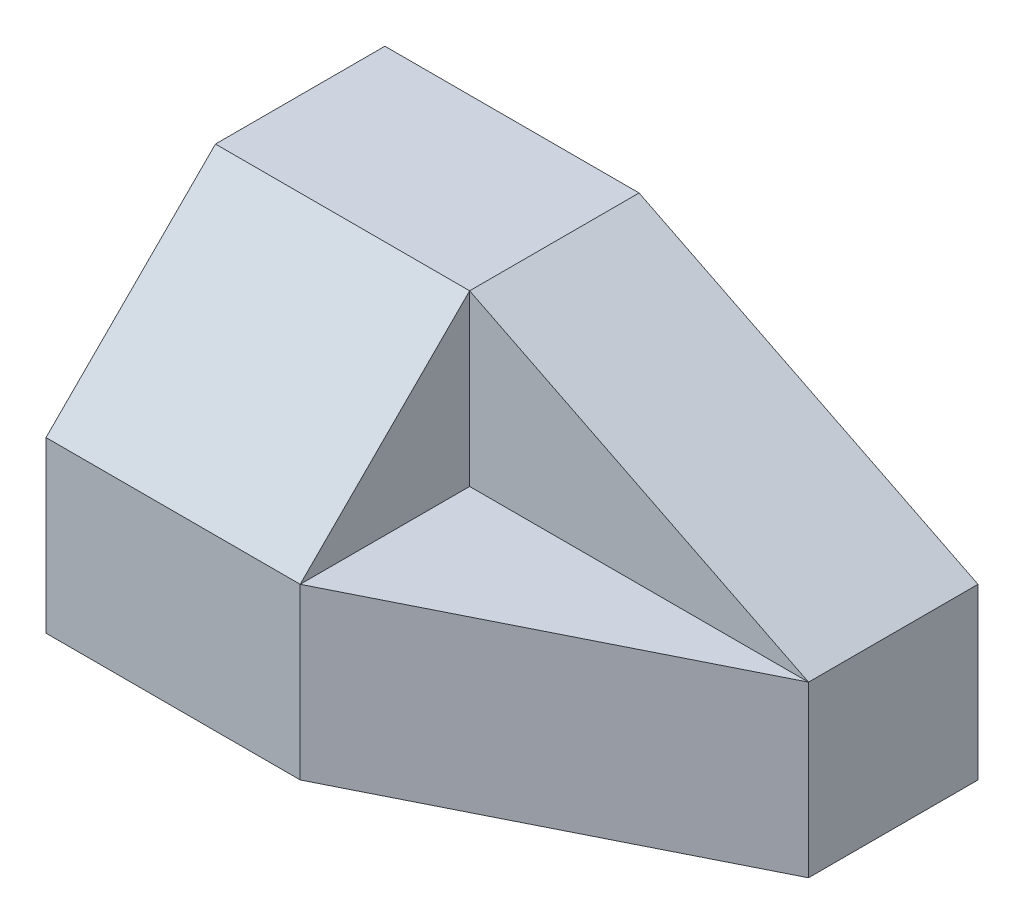
from build123d import *

# Parameters (mm, degrees)
SKETCH_1_W          = 7
SKETCH_1_H          = 4
EXTRUDE_1_DEPTH     = 4
CUT_EXTRUDE_1_DEPTH = 4
CUT_EXTRUDE_2_DEPTH = 6.4
CUT_EXTRUDE_3_DEPTH = 2
CUT_EXTRUDE_4_DEPTH = 3.8


with BuildPart() as part:
    # 草圖1 → 填料-伸長1 (new body)
    with BuildSketch(Plane(origin=(0, 0, 0), x_dir=(1, 0, 0), z_dir=(0, 1, 0))):
        Rectangle(SKETCH_1_W, SKETCH_1_H)
    extrude(amount=EXTRUDE_1_DEPTH)

    # 草圖2 → 除料-伸長1 (cut)
    with BuildSketch(Plane.XY.offset(2)):
        Polygon((3.5, 4), (-0.5, 4), (3.5, 2), align=None)
    extrude(amount=-CUT_EXTRUDE_1_DEPTH, mode=Mode.SUBTRACT)

    # 草圖3 → 除料-伸長2 (cut)
    with BuildSketch(Plane(origin=(0, 0, 0), x_dir=(1, 0, 0), z_dir=(0, 1, 0))):
        Polygon((-0.5, -2), (3.5, -2), (3.5, 0), align=None)
    extrude(amount=CUT_EXTRUDE_2_DEPTH, mode=Mode.SUBTRACT)

    # 草圖4 → 除料-伸長3 (cut)
    with BuildSketch(Plane(origin=(0, 4, 0), x_dir=(1, 0, 0), z_dir=(0, 1, 0))):
        Polygon((3.5, 0), (-0.5, 0), (-0.5, -2), align=None)
    extrude(amount=-CUT_EXTRUDE_3_DEPTH, mode=Mode.SUBTRACT)

    # 草圖5 → 除料-伸長4 (cut)
    with BuildSketch(Plane(origin=(-0.5, 0, 0), x_dir=(0, 0, -1), z_dir=(1, 0, 0))):
        Polygon((0, 4), (-2, 4), (-2, 2), align=None)
    extrude(amount=-CUT_EXTRUDE_4_DEPTH, mode=Mode.SUBTRACT)


solid = part.part
